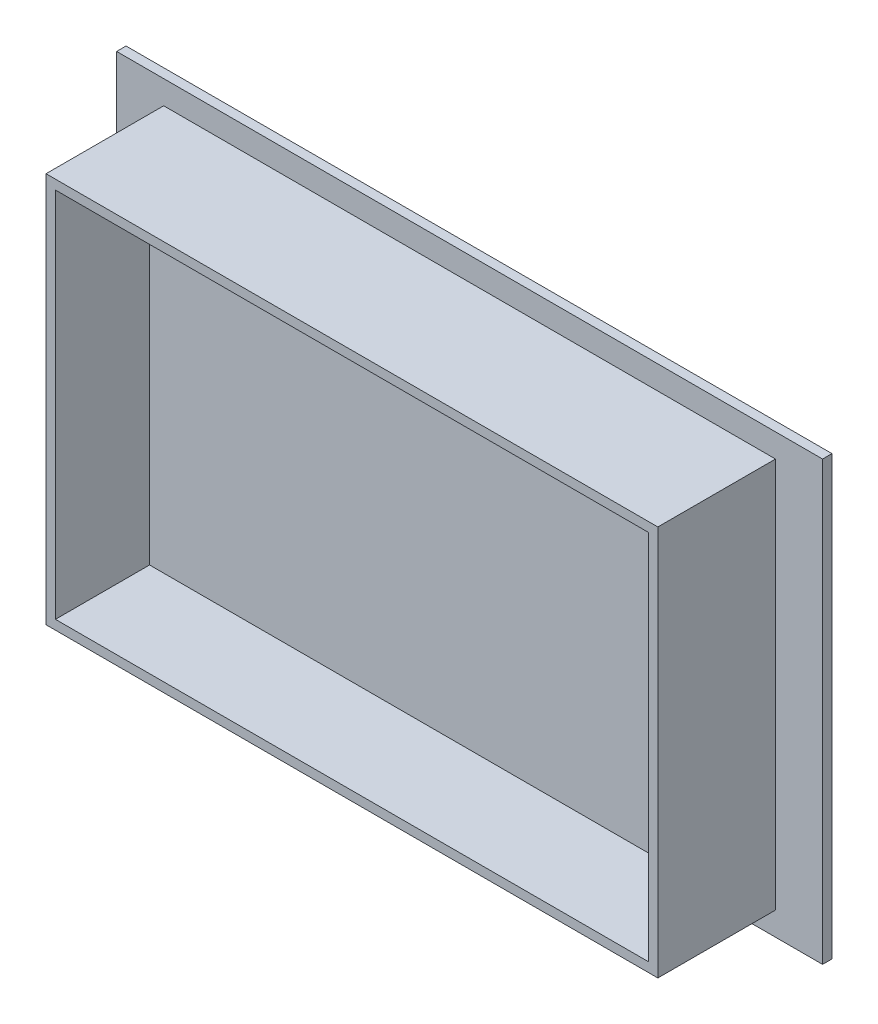
from build123d import *

# Parameters (mm, degrees)
SKETCH_1_W          = 150
SKETCH_1_H          = 93
EXTRUDE_2_DEPTH     = 2
SKETCH_2_W          = 130
SKETCH_2_H          = 83
EXTRUDE_3_DEPTH     = 25
SKETCH_3_W          = 126
SKETCH_3_H          = 79
CUT_EXTRUDE_1_DEPTH = 2
SKETCH_4_W          = 126
SKETCH_4_H          = 79
CUT_EXTRUDE_2_DEPTH = 20


with BuildPart() as part:
    # 草图1 → 凸台-拉伸2 (new body)
    with BuildSketch(Plane.XY):
        with Locations((8.786617008, -6.973744962)):
            Rectangle(SKETCH_1_W, SKETCH_1_H)
    extrude(amount=EXTRUDE_2_DEPTH)

    # 草图2 → 凸台-拉伸3 (add)
    with BuildSketch(Plane.XY.offset(2)):
        with Locations((8.786617008, -6.973744962)):
            Rectangle(SKETCH_2_W, SKETCH_2_H)
    extrude(amount=EXTRUDE_3_DEPTH)

    # 草图3 → 切除-拉伸1 (cut)
    with BuildSketch(Plane(origin=(0, 0, 0), x_dir=(-1, 0, 0), z_dir=(0, 0, -1))):
        with Locations((-8.786617008, -6.973744962)):
            Rectangle(SKETCH_3_W, SKETCH_3_H)
    extrude(amount=-CUT_EXTRUDE_1_DEPTH, mode=Mode.SUBTRACT)

    # 草图4 → 切除-拉伸2 (cut)
    with BuildSketch(Plane.XY.offset(27)):
        with Locations((8.786617008, -6.973744962)):
            Rectangle(SKETCH_4_W, SKETCH_4_H)
    extrude(amount=-CUT_EXTRUDE_2_DEPTH, mode=Mode.SUBTRACT)


solid = part.part
